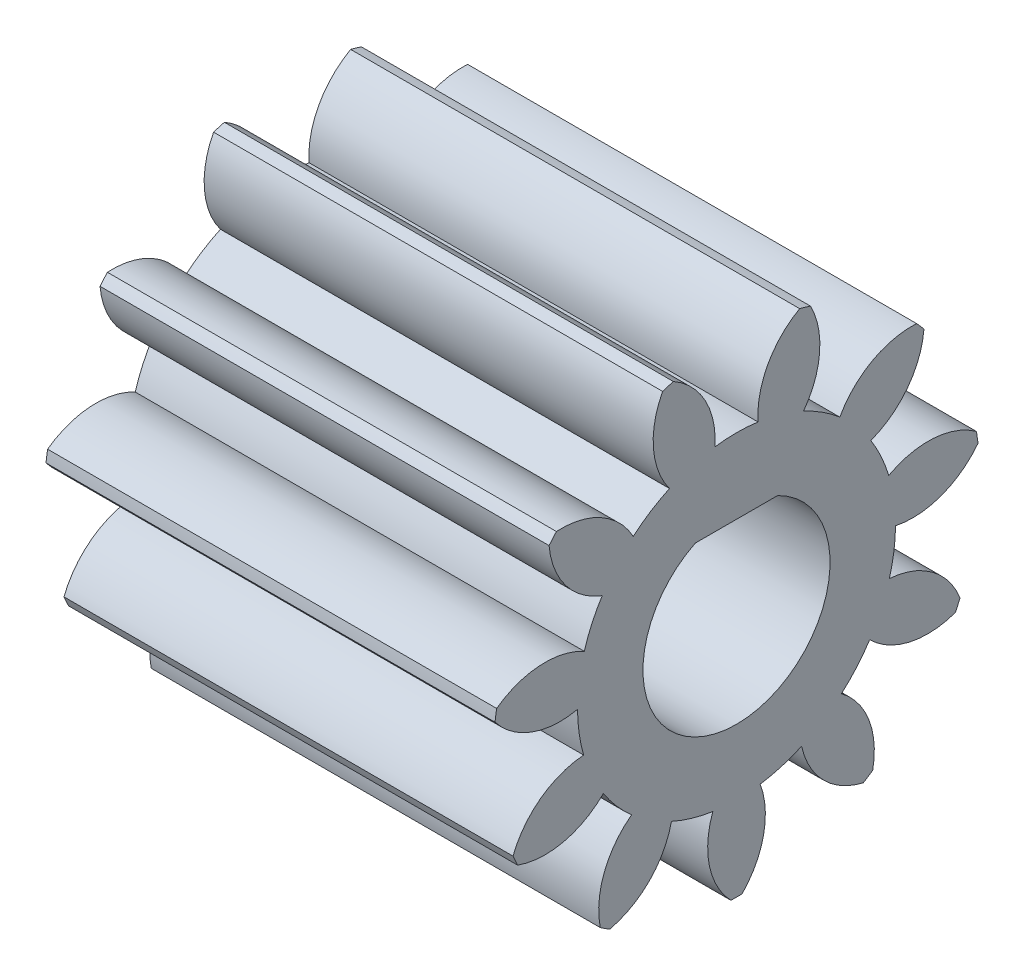
from build123d import *

# Parameters (mm, degrees)
BASPROSKE_W         = 12
BASPROSKE_H         = 6.5
TOOTHCUT_DEPTH      = 16.116216458
TEETHCUTS_COUNT     = 11
TEETHCUTS_ANGLE     = 327.272727273
BORSKE_R            = 2.5
BORE_DEPTH          = 50.0000508
BOSS_EXTRUDE1_DEPTH = 12


with BuildPart() as part:
    # BasProSke → Base-Revolve (revolve)
    with BuildSketch(Plane(origin=(0, 0, 0), x_dir=(1, 0, 0), z_dir=(0, 1, 0)), mode=Mode.PRIVATE) as base_revolve_sk:
        with Locations((6, 3.25)):
            Rectangle(BASPROSKE_W, BASPROSKE_H)
    revolve(base_revolve_sk.sketch.rotate(Axis((-10, 0, 0), (1, 0, 0)), 180), axis=Axis((-10, 0, 0), (1, 0, 0)))

    # TooCutSke → ToothCut (cut, through all)
    with BuildSketch(Plane(origin=(0, 0, 0), x_dir=(0, 0, -1), z_dir=(1, 0, 0))):
        with BuildLine():
            ThreePointArc((0.576045815, 4.209771041), (0, 4.249), (-0.576045815, 4.209771041))
            ThreePointArc((-0.576045815, 4.209771041), (-0.841371334, 5.420048739), (-1.718652745, 6.295004202))
            ThreePointArc((-1.718652745, 6.295004202), (0, 6.5254), (1.718652745, 6.295004202))
            ThreePointArc((1.718652745, 6.295004202), (0.841371334, 5.420048739), (0.576045815, 4.209771041))
        make_face()
    toothcut = extrude(amount=TOOTHCUT_DEPTH, mode=Mode.SUBTRACT)

    # TeethCuts: ToothCut ×11 about axis
    teethcuts_axis = Axis((-10, 0, 0), (1, 0, 0))
    for i in range(1, TEETHCUTS_COUNT):
        add(toothcut.rotate(teethcuts_axis, i * TEETHCUTS_ANGLE / (TEETHCUTS_COUNT - 1)), mode=Mode.SUBTRACT)

    # BorSke → Bore (cut, symmetric)
    with BuildSketch(Plane(origin=(0, 0, 0), x_dir=(0, 0, -1), z_dir=(1, 0, 0))):
        with Locations(Location((0, 0, 0), (0, 0, 180))):
            Circle(BORSKE_R)
    extrude(amount=BORE_DEPTH, both=True, mode=Mode.SUBTRACT)

    # Sketch1 → Boss-Extrude1 (add)
    with BuildSketch(Plane(origin=(12, 0, 0), x_dir=(0, 0, -1), z_dir=(1, 0, 0))):
        with BuildLine():
            Line((-1.1, 2.244994432), (1.1, 2.244994432))
            ThreePointArc((1.1, 2.244994432), (0, 2.5), (-1.1, 2.244994432))
        make_face()
    extrude(amount=-BOSS_EXTRUDE1_DEPTH)


solid = part.part
